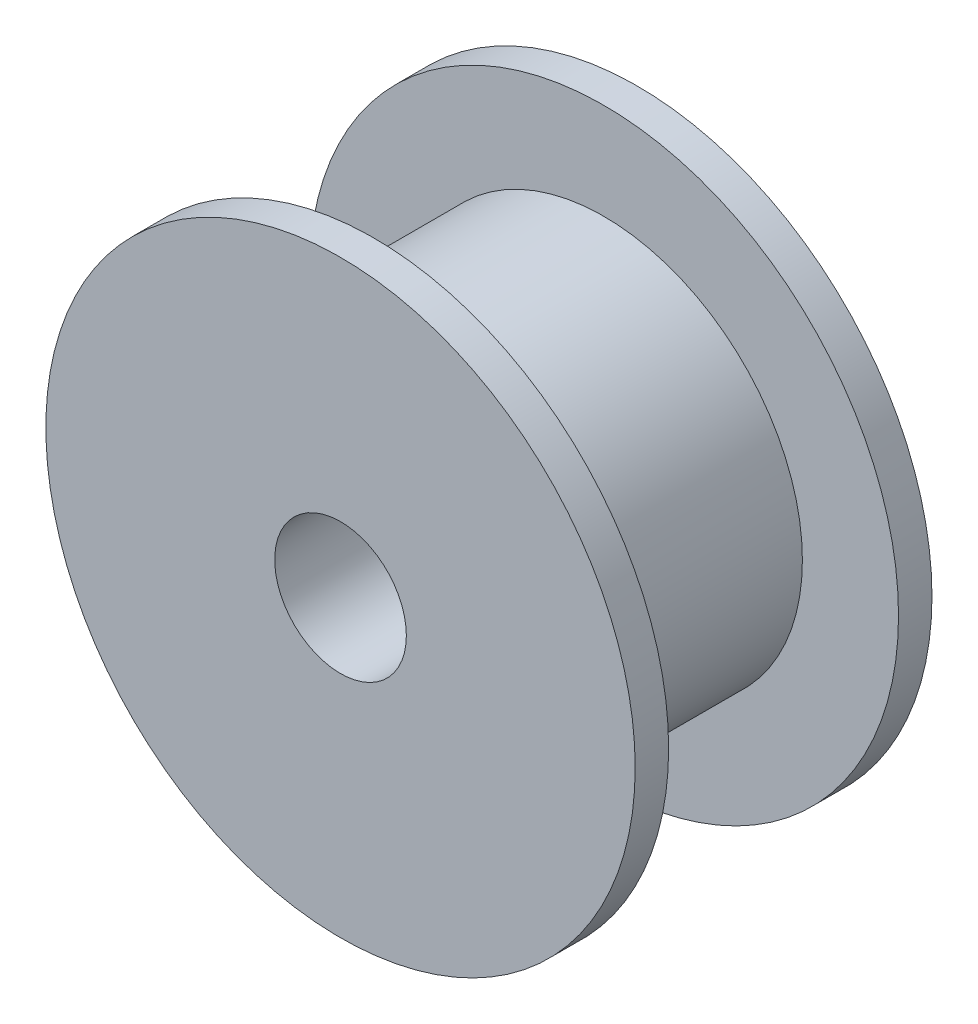
from build123d import *

# Parameters (mm, degrees)
SKETCH1_R           = 8.9535
SKETCH1_R_2         = 2
BOSS_EXTRUDE1_DEPTH = 1.016
SKETCH2_R           = 6.0325
SKETCH2_R_2         = 2
BOSS_EXTRUDE2_DEPTH = 6.985
SKETCH3_R           = 8.9535
SKETCH3_R_2         = 2
BOSS_EXTRUDE3_DEPTH = 1.016


with BuildPart() as part:
    # Sketch1 → Boss-Extrude1 (new body)
    with BuildSketch(Plane.XY):
        Circle(SKETCH1_R)
        Circle(SKETCH1_R_2, mode=Mode.SUBTRACT)
    extrude(amount=BOSS_EXTRUDE1_DEPTH)

    # Sketch2 → Boss-Extrude2 (add)
    with BuildSketch(Plane.XY.offset(1.016)):
        Circle(SKETCH2_R)
        Circle(SKETCH2_R_2, mode=Mode.SUBTRACT)
    extrude(amount=BOSS_EXTRUDE2_DEPTH)

    # Sketch3 → Boss-Extrude3 (add)
    with BuildSketch(Plane.XY.offset(8.001)):
        Circle(SKETCH3_R)
        Circle(SKETCH3_R_2, mode=Mode.SUBTRACT)
    extrude(amount=BOSS_EXTRUDE3_DEPTH)


solid = part.part
